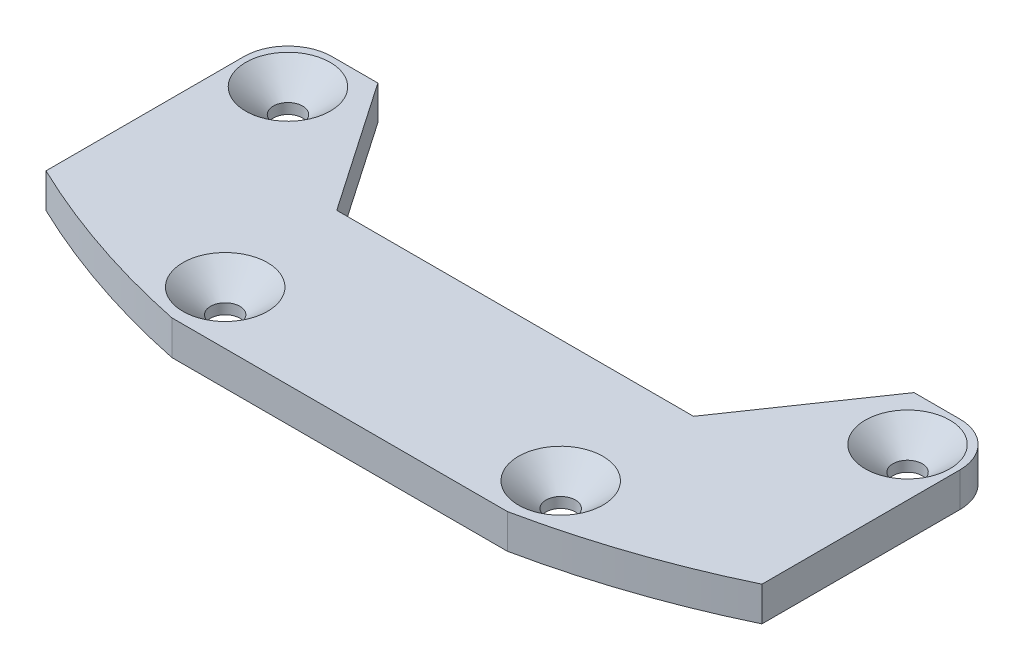
from build123d import *

# Parameters (mm, degrees)
SKETCH1_R           = 1.35255
BOSS_EXTRUDE1_DEPTH = 3.175
CHAMFER2_SIZE       = 2.54635
CHAMFER2_SIZE2      = 2.213508285


with BuildPart() as part:
    # Sketch1 → Boss-Extrude1 (new body)
    with BuildSketch(Plane(origin=(0, 0, 0), x_dir=(1, 0, 0), z_dir=(0, 1, 0))):
        with BuildLine():
            Line((-24.73005605, 14.12875), (-16.454266742, 2.06375))
            Line((-16.454266742, 2.06375), (16.454266742, 2.06375))
            Line((16.454266742, 2.06375), (24.73005605, 14.12875))
            Line((24.73005605, 14.12875), (28.956, 14.12875))
            ThreePointArc((28.956, 14.12875), (31.829681959, 12.938431959), (33.02, 10.06475))
            Line((33.02, 10.06475), (33.02, -8.19025964))
            ThreePointArc((33.02, -8.19025964), (24.427649347, -11.694709026), (15.473036022, -14.12875))
            Line((15.473036022, -14.12875), (-15.473036022, -14.12875))
            ThreePointArc((-15.473036022, -14.12875), (-24.427649347, -11.694709026), (-33.02, -8.19025964))
            Line((-33.02, -8.19025964), (-33.02, 10.06475))
            ThreePointArc((-33.02, 10.06475), (-31.829681959, 12.938431959), (-28.956, 14.12875))
            Line((-28.956, 14.12875), (-24.73005605, 14.12875))
        make_face()
        with Locations((-28.575, 9.68375)):
            Circle(SKETCH1_R, mode=Mode.SUBTRACT)
        with Locations((-15.473036022, -9.2075)):
            Circle(SKETCH1_R, mode=Mode.SUBTRACT)
        with Locations((15.473036022, -9.2075)):
            Circle(SKETCH1_R, mode=Mode.SUBTRACT)
        with Locations((28.575, 9.68375)):
            Circle(SKETCH1_R, mode=Mode.SUBTRACT)
    extrude(amount=BOSS_EXTRUDE1_DEPTH)

    # Chamfer2
    chamfer2_edges = [part.edges().sort_by_distance(p)[0] for p in [
        (-16.825586022, 3.175, 9.2075),
        (-29.92755, 3.175, -9.68375),
        (14.120486022, 3.175, 9.2075),
        (27.22245, 3.175, -9.68375),
    ]]
    chamfer2_side = [part.faces().sort_by_distance(p)[0] for p in [
        (0, 3.175, 2.574836874),
    ]]
    chamfer(chamfer2_edges, length=CHAMFER2_SIZE, length2=CHAMFER2_SIZE2, reference=chamfer2_side[0])


solid = part.part
